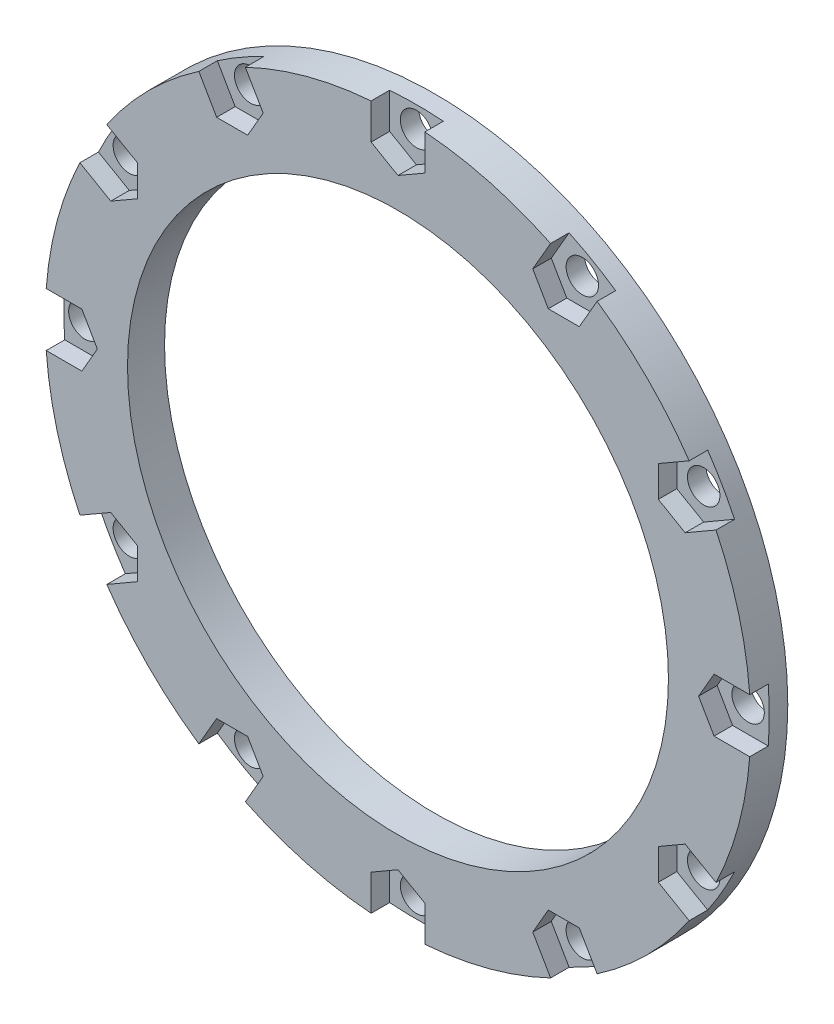
from build123d import *

# Parameters (mm, degrees)
SKETCH1_R           = 38.1
SKETCH1_R_2         = 29.21
BOSS_EXTRUDE1_DEPTH = 4
SKETCH2_R           = 1.75
CUT_EXTRUDE1_DEPTH  = 5
CUT_EXTRUDE2_DEPTH  = 2


with BuildPart() as part:
    # Sketch1 → Boss-Extrude1 (new body)
    with BuildSketch(Plane.XY):
        Circle(SKETCH1_R)
        Circle(SKETCH1_R_2, mode=Mode.SUBTRACT)
    extrude(amount=BOSS_EXTRUDE1_DEPTH)

    # Sketch2 → Cut-Extrude1 (cut, through all)
    with BuildSketch(Plane.XY.offset(4)):
        with Locations((0, 35.814)):
            Circle(SKETCH2_R)
        with Locations((17.907, 31.015833811)):
            Circle(SKETCH2_R)
        with Locations((31.015833811, 17.907)):
            Circle(SKETCH2_R)
        with Locations((35.814, 0)):
            Circle(SKETCH2_R)
        with Locations((31.015833811, -17.907)):
            Circle(SKETCH2_R)
        with Locations((17.907, -31.015833811)):
            Circle(SKETCH2_R)
        with Locations((0, -35.814)):
            Circle(SKETCH2_R)
        with Locations((-17.907, -31.015833811)):
            Circle(SKETCH2_R)
        with Locations((-31.015833811, -17.907)):
            Circle(SKETCH2_R)
        with Locations((-35.814, 0)):
            Circle(SKETCH2_R)
        with Locations((-31.015833811, 17.907)):
            Circle(SKETCH2_R)
        with Locations((-17.907, 31.015833811)):
            Circle(SKETCH2_R)
    extrude(amount=-CUT_EXTRUDE1_DEPTH, mode=Mode.SUBTRACT)

    # Sketch3 → Cut-Extrude2 (cut)
    with BuildSketch(Plane.XY.offset(4)):
        Polygon((-2.9, 37.989472226), (0, 39.162631561), (2.9, 37.989472226), (2.9, 34.139684219), (0, 32.465368439), (-2.9, 34.139684219), align=None)
        Polygon((16.483262442, 34.349848024), (19.581315781, 33.915833811), (21.506209784, 31.449848024), (19.581315781, 28.115833811), (16.232684219, 28.115833811), (14.558368439, 31.015833811), align=None)
        Polygon((31.449848024, 21.506209784), (33.915833811, 19.581315781), (34.349848024, 16.483262442), (31.015833811, 14.558368439), (28.115833811, 16.232684219), (28.115833811, 19.581315781), align=None)
        Polygon((37.989472226, 2.9), (39.162631561, 0), (37.989472226, -2.9), (34.139684219, -2.9), (32.465368439, 0), (34.139684219, 2.9), align=None)
        Polygon((34.349848024, -16.483262442), (33.915833811, -19.581315781), (31.449848024, -21.506209784), (28.115833811, -19.581315781), (28.115833811, -16.232684219), (31.015833811, -14.558368439), align=None)
        Polygon((21.506209784, -31.449848024), (19.581315781, -33.915833811), (16.483262442, -34.349848024), (14.558368439, -31.015833811), (16.232684219, -28.115833811), (19.581315781, -28.115833811), align=None)
        Polygon((2.9, -37.989472226), (0, -39.162631561), (-2.9, -37.989472226), (-2.9, -34.139684219), (0, -32.465368439), (2.9, -34.139684219), align=None)
        Polygon((-16.483262442, -34.349848024), (-19.581315781, -33.915833811), (-21.506209784, -31.449848024), (-19.581315781, -28.115833811), (-16.232684219, -28.115833811), (-14.558368439, -31.015833811), align=None)
        Polygon((-31.449848024, -21.506209784), (-33.915833811, -19.581315781), (-34.349848024, -16.483262442), (-31.015833811, -14.558368439), (-28.115833811, -16.232684219), (-28.115833811, -19.581315781), align=None)
        Polygon((-37.989472226, -2.9), (-39.162631561, 0), (-37.989472226, 2.9), (-34.139684219, 2.9), (-32.465368439, 0), (-34.139684219, -2.9), align=None)
        Polygon((-34.349848024, 16.483262442), (-33.915833811, 19.581315781), (-31.449848024, 21.506209784), (-28.115833811, 19.581315781), (-28.115833811, 16.232684219), (-31.015833811, 14.558368439), align=None)
        Polygon((-21.506209784, 31.449848024), (-19.581315781, 33.915833811), (-16.483262442, 34.349848024), (-14.558368439, 31.015833811), (-16.232684219, 28.115833811), (-19.581315781, 28.115833811), align=None)
    extrude(amount=-CUT_EXTRUDE2_DEPTH, mode=Mode.SUBTRACT)


solid = part.part
